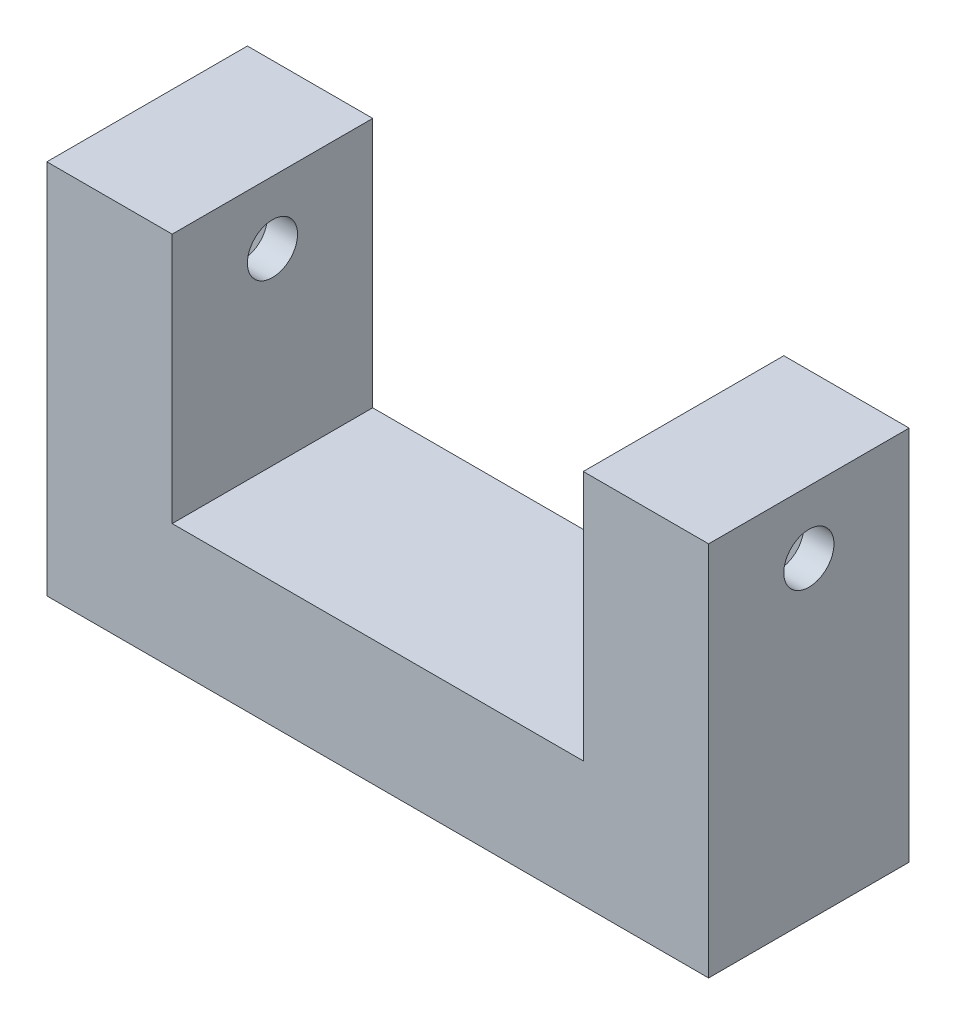
from build123d import *

# Parameters (mm, degrees)
EXTRUDE_1_DEPTH     = 8
CUT_EXTRUDE_START   = -1
SKETCH_3_W          = 2.6
SKETCH_3_H          = 4.7
CUT_EXTRUDE_1_DEPTH = 15
SKETCH_4_R          = 1
CUT_EXTRUDE_2_DEPTH = 27.4
CHAMFER_1_SIZE      = 0.2


with BuildPart() as part:
    # Эскиз2 → Бобышка-Вытянуть1 (new body)
    with BuildSketch(Plane.XY):
        Polygon((21.4, -5), (21.4, 10), (16.4, 10), (16.4, 0), (0, 0), (0, 10), (-5, 10), (-5, -5), align=None)
    extrude(amount=EXTRUDE_1_DEPTH)

    # Эскиз3 → Вырез-Вытянуть1 (cut, through all)
    with BuildSketch(Plane(origin=(0, 10, 0), x_dir=(1, 0, 0), z_dir=(0, 1, 0)).offset(CUT_EXTRUDE_START)):
        with Locations((-2.5, -4)):
            Rectangle(SKETCH_3_W, SKETCH_3_H)
        with Locations((18.9, -4)):
            Rectangle(SKETCH_3_W, SKETCH_3_H)
    extrude(amount=-CUT_EXTRUDE_1_DEPTH, mode=Mode.SUBTRACT)

    # Эскиз4 → Вырез-Вытянуть2 (cut, through all)
    with BuildSketch(Plane(origin=(21.4, 0, 0), x_dir=(0, 0, -1), z_dir=(1, 0, 0))):
        with Locations((-4, 7.5)):
            Circle(SKETCH_4_R)
    extrude(amount=-CUT_EXTRUDE_2_DEPTH, mode=Mode.SUBTRACT)

    # Фаска1
    chamfer_1_edges = [part.edges().sort_by_distance(p)[0] for p in [
        (-1.2, -5, 4),
        (-2.5, -5, 6.35),
        (-3.8, -5, 4),
        (-2.5, -5, 1.65),
        (20.2, -5, 4),
        (18.9, -5, 6.35),
        (17.6, -5, 4),
        (18.9, -5, 1.65),
    ]]
    chamfer(chamfer_1_edges, length=CHAMFER_1_SIZE)


solid = part.part
